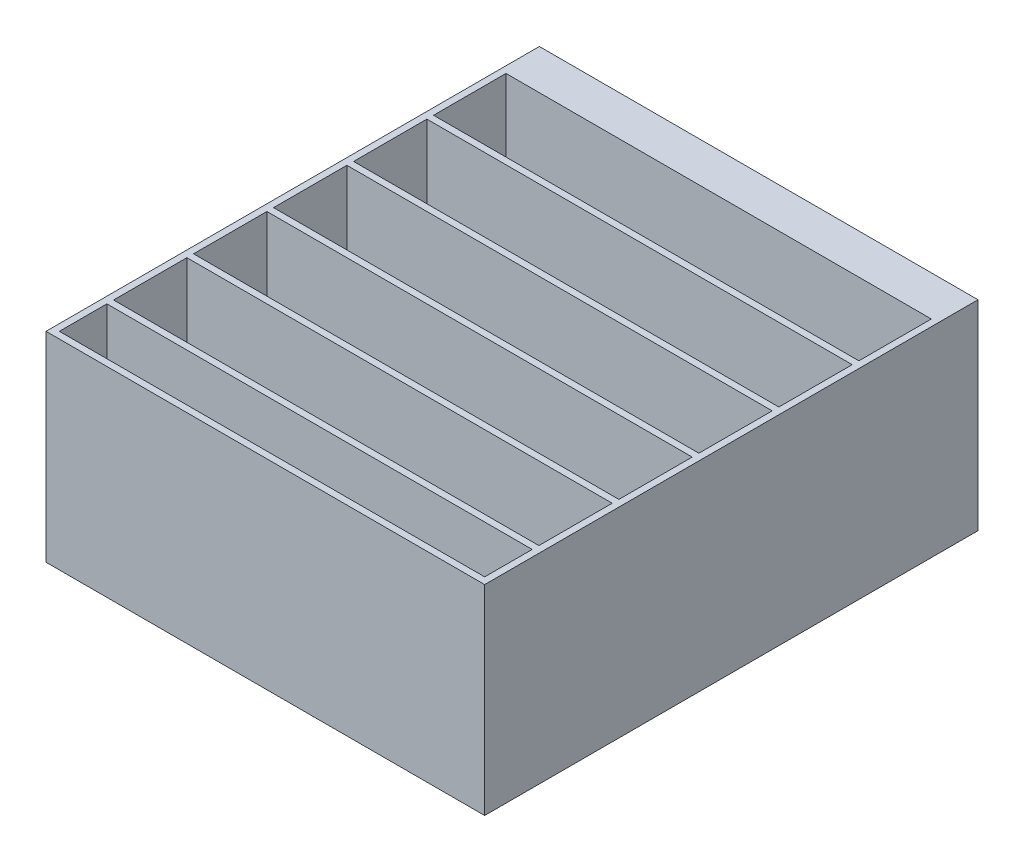
from build123d import *

# Parameters (mm, degrees)
ESQUISSE1_W             = 329
ESQUISSE1_H             = 150
BOSS_EXTRU_1_DEPTH      = 370
ESQUISSE2_W             = 319
ESQUISSE2_H             = 335
ENL_V_MAT_EXTRU_1_DEPTH = 90
ESQUISSE3_W             = 209
ESQUISSE3_H             = 10.713791462
ENL_V_MAT_EXTRU_2_DEPTH = 30
ESQUISSE4_W             = 208.8
ESQUISSE4_H             = 8.713791462
ENL_V_MAT_EXTRU_3_DEPTH = 30
ESQUISSE6_W             = 90.150575604
ESQUISSE6_H             = 11.402147775
BOSS_EXTRU_3_DEPTH      = 30
ESQUISSE7_W             = 5
ESQUISSE7_H             = 90
BOSS_EXTRU_4_DEPTH      = 329
ESQUISSE8_W             = 5
ESQUISSE8_H             = 92.498011514
BOSS_EXTRU_5_DEPTH      = 329
ESQUISSE9_W             = 5
ESQUISSE9_H             = 90
BOSS_EXTRU_6_DEPTH      = 329
ESQUISSE10_W            = 5
ESQUISSE10_H            = 90
BOSS_EXTRU_7_DEPTH      = 329
ESQUISSE11_W            = 5
ESQUISSE11_H            = 91.858335329
BOSS_EXTRU_8_DEPTH      = 329


with BuildPart() as part:
    # Esquisse1 → Boss.-Extru.1 (new body)
    with BuildSketch(Plane.XY):
        with Locations((55.821656051, -51.75955414)):
            Rectangle(ESQUISSE1_W, ESQUISSE1_H)
    extrude(amount=BOSS_EXTRU_1_DEPTH)

    # Esquisse2 → Enlèv. mat.-Extru.1 (cut)
    with BuildSketch(Plane(origin=(0, 23.24044586, 0), x_dir=(1, 0, 0), z_dir=(0, 1, 0))):
        with Locations((55.821656051, -197.5)):
            Rectangle(ESQUISSE2_W, ESQUISSE2_H)
    extrude(amount=-ENL_V_MAT_EXTRU_1_DEPTH, mode=Mode.SUBTRACT)

    # Esquisse3 → Enlèv. mat.-Extru.2 (cut)
    with BuildSketch(Plane(origin=(0, -126.75955414, 0), x_dir=(-1, 0, 0), z_dir=(0, -1, 0))):
        with Locations((-55.821656051, -5.356895731)):
            Rectangle(ESQUISSE3_W, ESQUISSE3_H)
    extrude(amount=-ENL_V_MAT_EXTRU_2_DEPTH, mode=Mode.SUBTRACT)

    # Esquisse4 → Enlèv. mat.-Extru.3 (cut)
    with BuildSketch(Plane(origin=(0, -96.75955414, 0), x_dir=(-1, 0, 0), z_dir=(0, -1, 0))):
        with Locations((-55.821656051, -6.356895731)):
            Rectangle(ESQUISSE4_W, ESQUISSE4_H)
    extrude(amount=-ENL_V_MAT_EXTRU_3_DEPTH, mode=Mode.SUBTRACT)

    # Esquisse6 → Boss.-Extru.3 (add)
    with BuildSketch(Plane(origin=(0, -66.75955414, 0), x_dir=(-1, 0, 0), z_dir=(0, -1, 0))):
        with Locations((3.603056147, -11.057969619)):
            Rectangle(ESQUISSE6_W, ESQUISSE6_H)
    extrude(amount=-BOSS_EXTRU_3_DEPTH)

    # Esquisse7 → Boss.-Extru.4 (add)
    with BuildSketch(Plane.ZY.offset(108.678343949)):
        with Locations((86.839910946, -21.75955414)):
            Rectangle(ESQUISSE7_W, ESQUISSE7_H)
    extrude(amount=-BOSS_EXTRU_4_DEPTH)

    # Esquisse8 → Boss.-Extru.5 (add)
    with BuildSketch(Plane.ZY.offset(108.678343949)):
        with Locations((146.839910946, -23.008559897)):
            Rectangle(ESQUISSE8_W, ESQUISSE8_H)
    extrude(amount=-BOSS_EXTRU_5_DEPTH)

    # Esquisse9 → Boss.-Extru.6 (add)
    with BuildSketch(Plane.ZY.offset(108.678343949)):
        with Locations((206.839910946, -21.75955414)):
            Rectangle(ESQUISSE9_W, ESQUISSE9_H)
    extrude(amount=-BOSS_EXTRU_6_DEPTH)

    # Esquisse10 → Boss.-Extru.7 (add)
    with BuildSketch(Plane.ZY.offset(108.678343949)):
        with Locations((266.839910946, -21.75955414)):
            Rectangle(ESQUISSE10_W, ESQUISSE10_H)
    extrude(amount=-BOSS_EXTRU_7_DEPTH)

    # Esquisse11 → Boss.-Extru.8 (add)
    with BuildSketch(Plane.ZY.offset(108.678343949)):
        with Locations((326.839910946, -22.688721805)):
            Rectangle(ESQUISSE11_W, ESQUISSE11_H)
    extrude(amount=-BOSS_EXTRU_8_DEPTH)


solid = part.part
